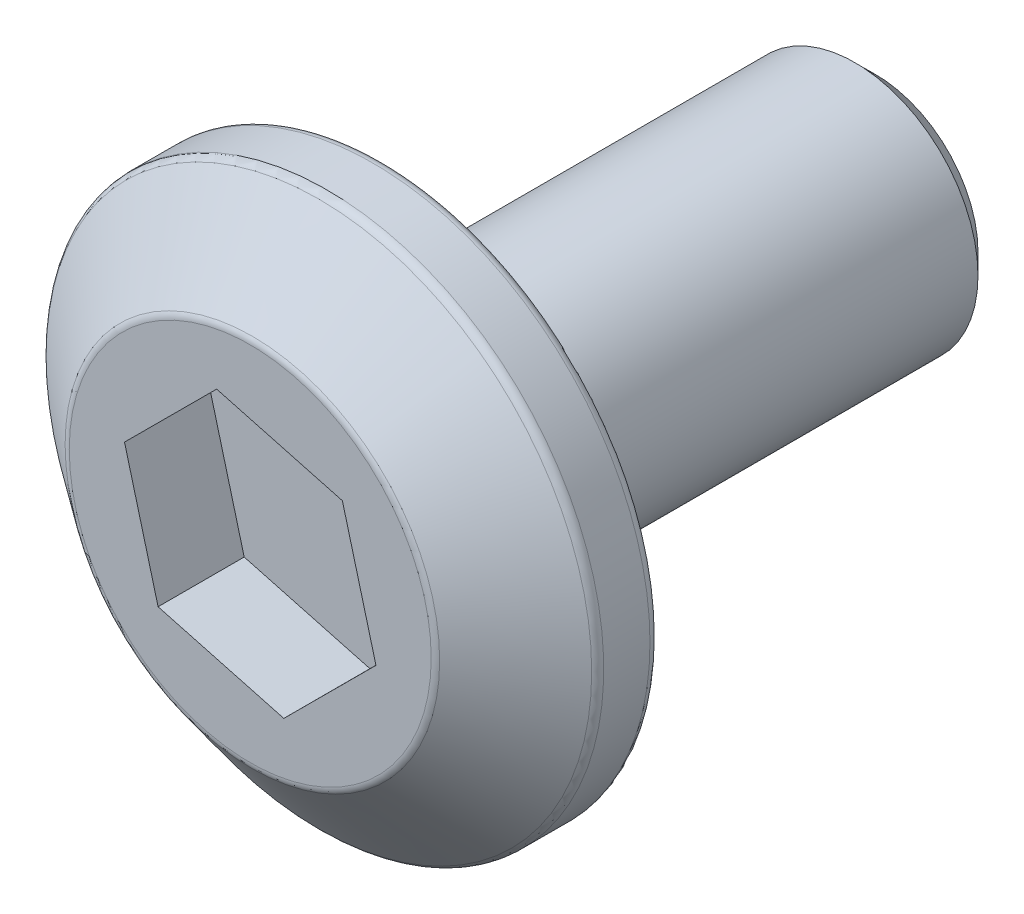
from build123d import *

# Parameters (mm, degrees)
SKETCH1_R           = 3
BOSS_EXTRUDE1_DEPTH = 12
SKETCH2_R           = 6.75
BOSS_EXTRUDE2_DEPTH = 1.5
SKETCH3_R           = 4.5
FILLET1_R           = 0.25
CUT_EXTRUDE1_DEPTH  = 2.1
CHAMFER2_SIZE       = 0.5


with BuildPart() as part:
    # Sketch1 → Boss-Extrude1 (new body)
    with BuildSketch(Plane.XY):
        Circle(SKETCH1_R)
    extrude(amount=BOSS_EXTRUDE1_DEPTH)

    # Sketch2 → Boss-Extrude2 (add)
    with BuildSketch(Plane.XY.offset(12)):
        Circle(SKETCH2_R)
    extrude(amount=BOSS_EXTRUDE2_DEPTH)

    # Sketch3 → section 1 of loft1
    with BuildSketch(Plane.XY.offset(15.25), mode=Mode.PRIVATE) as loft1_s1:
        Circle(SKETCH3_R)
    # loft up to a face of the part (loft1)
    loft([Face(Wire([part.edges().sort_by_distance((-4.620692965, 4.920538235, 13.5))[0]])), loft1_s1.sketch])

    # Fillet1
    fillet1_edges = [part.edges().sort_by_distance(p)[0] for p in [
        (-6.75, 0, 12),
        (-6.75, 0, 13.5),
        (-4.5, 0, 15.25),
    ]]
    fillet(fillet1_edges, radius=FILLET1_R)

    # Sketch6 → Cut-Extrude1 (cut)
    with BuildSketch(Plane.XY.offset(15.25)):
        Polygon((3.066485121, -0.824622541), (2.24738663, 2.243342745), (-0.819098491, 3.067965286), (-3.066485121, 0.824622541), (-2.24738663, -2.243342745), (0.819098491, -3.067965286), align=None)
    extrude(amount=-CUT_EXTRUDE1_DEPTH, mode=Mode.SUBTRACT)

    # Chamfer2
    chamfer2_edges = [part.edges().sort_by_distance(p)[0] for p in [
        (-3, 0, 0),
    ]]
    chamfer(chamfer2_edges, length=CHAMFER2_SIZE)


solid = part.part
